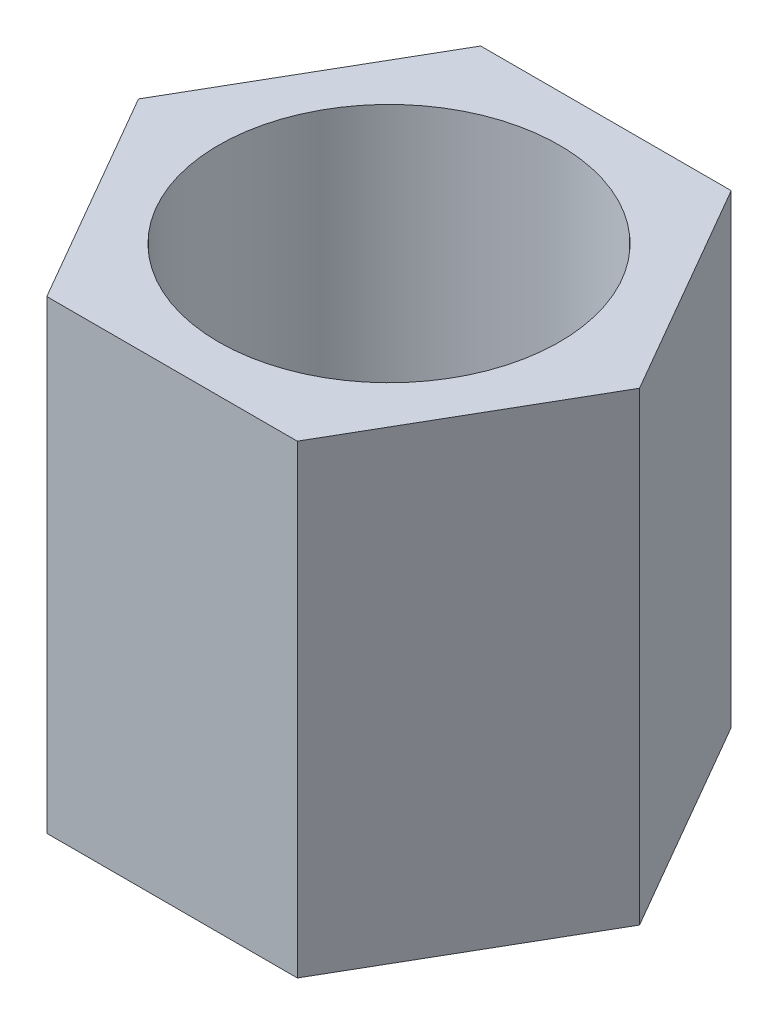
from build123d import *

# Parameters (mm, degrees)
EXTRUDE_1_DEPTH     = 3
SKETCH_2_R          = 1.1
CUT_EXTRUDE_1_DEPTH = 4


with BuildPart() as part:
    # 草图1 → 凸台-拉伸1 (new body)
    with BuildSketch(Plane(origin=(0, 0, 0), x_dir=(1, 0, 0), z_dir=(0, 1, 0))):
        Polygon((1.616580754, 0), (0.808290377, 1.4), (-0.808290377, 1.4), (-1.616580754, 0), (-0.808290377, -1.4), (0.808290377, -1.4), align=None)
    extrude(amount=EXTRUDE_1_DEPTH)

    # 草图2 → 切除-拉伸1 (cut, through all)
    with BuildSketch(Plane(origin=(0, 3, 0), x_dir=(1, 0, 0), z_dir=(0, 1, 0))):
        Circle(SKETCH_2_R)
    extrude(amount=-CUT_EXTRUDE_1_DEPTH, mode=Mode.SUBTRACT)


solid = part.part
